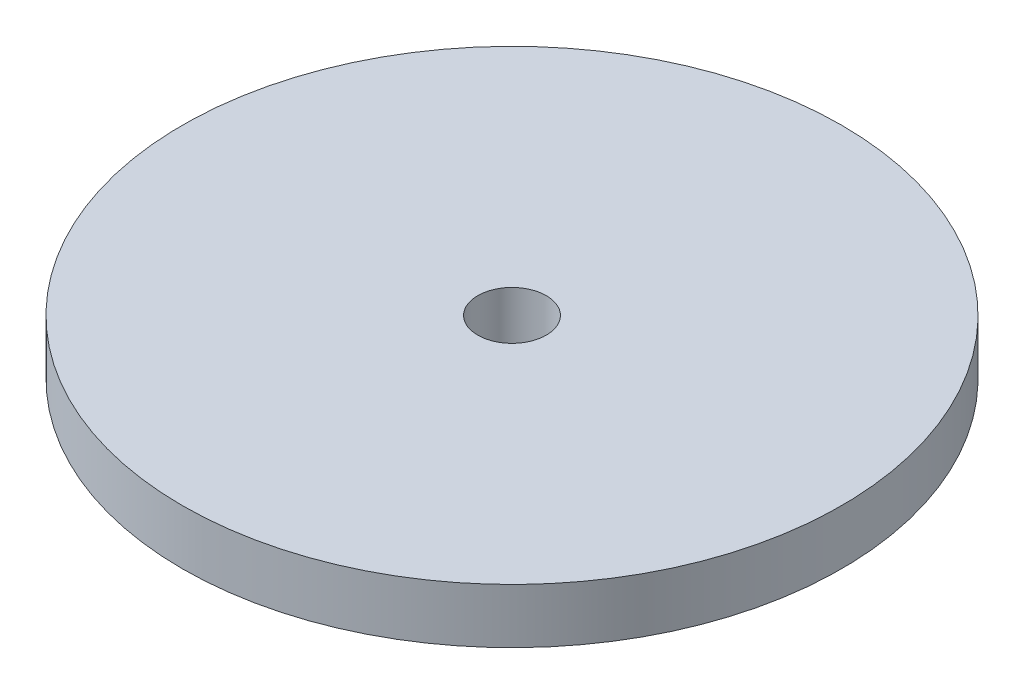
from build123d import *

# Parameters (mm, degrees)
SKETCH1_R           = 38.227
BOSS_EXTRUDE1_DEPTH = 6.35
SKETCH2_R           = 3.9751
CUT_EXTRUDE1_DEPTH  = 55.43279855


with BuildPart() as part:
    # Sketch1 → Boss-Extrude1 (new body)
    with BuildSketch(Plane(origin=(0, 0, 0), x_dir=(1, 0, 0), z_dir=(0, 1, 0))):
        Circle(SKETCH1_R)
    extrude(amount=BOSS_EXTRUDE1_DEPTH)

    # Sketch2 → Cut-Extrude1 (cut, through all)
    with BuildSketch(Plane(origin=(0, 6.35, 0), x_dir=(1, 0, 0), z_dir=(0, 1, 0))):
        Circle(SKETCH2_R)
    extrude(amount=-CUT_EXTRUDE1_DEPTH, mode=Mode.SUBTRACT)


solid = part.part
